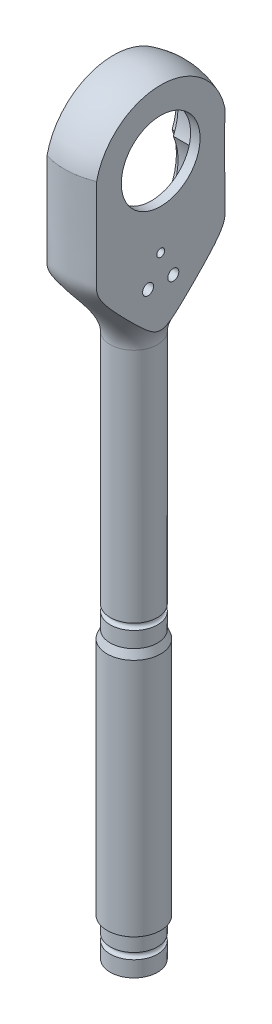
from build123d import *

# Parameters (mm, degrees)
WYTNIJ_WYCI_GNI_CIE1_DEPTH      = 248.984446753
WYTNIJ_WYCI_GNI_CIE1_DEPTH_BACK = 248.984446753
SZKIC2_W                        = 31.290574964
SZKIC2_H                        = 87.321210772
WYTNIJ_WYCI_GNI_CIE2_DEPTH      = 2
WYTNIJ_WYCI_GNI_CIE3_DEPTH      = 12
WYTNIJ_WYCI_GNI_CIE4_DEPTH      = 248.390668611
WYTNIJ_WYCI_GNI_CIE4_DEPTH_BACK = 248.390668611
SZKIC5_R                        = 1.75
SZKIC5_R_2                      = 1.25
SZKIC5_R_3                      = 12.5


with BuildPart() as part:
    # Szkic1 → Obrót1 (revolve)
    with BuildSketch(Plane.XY, mode=Mode.PRIVATE) as obr_t1_sk:
        with BuildLine():
            Line((0, 0), (7.5, 0))
            Line((7.5, 0), (7.5, 5))
            ThreePointArc((7.5, 5), (6.5, 6), (7.5, 7))
            Line((7.5, 7), (7.5, 11.25))
            ThreePointArc((7.5, 11.25), (7.719669914, 11.780330086), (8.25, 12))
            Line((8.25, 12), (8.5, 12))
            Line((8.5, 12), (8.5, 88))
            Line((8.5, 88), (7.5, 90.5))
            Line((7.5, 90.5), (7.5, 95.5))
            ThreePointArc((7.5, 95.5), (6.5, 96.5), (7.5, 97.5))
            Line((7.5, 97.5), (7.5, 172.5))
            add(Edge.make_bspline(
                [(7.5, 172.5), (7.5, 180.6), (22.382394371, 192.832212865), (21.895583134, 206.484053927), (22.045407685, 220.5), (22.045407685, 228)],
                knots=[0, 0, 0, 0, 0.361711038, 0.461711038, 1, 1, 1, 1], degree=3))
            ThreePointArc((22.045407685, 228), (14.230249471, 240.928425058), (0, 246))
            Line((0, 246), (0, 0))
        make_face()
    revolve(obr_t1_sk.sketch.rotate(Axis((0, 0, 0), (0, 1, 0)), 90), axis=Axis((0, 0, 0), (0, 1, 0)))

    # Szkic2 → Wytnij-wyciągnięcie1 (cut, two sides: drawn at the far end of the back side and taken through both)
    with BuildSketch(Plane.XY.offset(-WYTNIJ_WYCI_GNI_CIE1_DEPTH_BACK)):
        Polygon((-7.5, 168), (-6.5, 173), (-6.5, 255.321210772), (-63.324406691, 255.321210772), (-63.324406691, 168), align=None)
        with Locations((24.145287482, 211.660605386)):
            Rectangle(SZKIC2_W, SZKIC2_H)
    extrude(amount=WYTNIJ_WYCI_GNI_CIE1_DEPTH + WYTNIJ_WYCI_GNI_CIE1_DEPTH_BACK, mode=Mode.SUBTRACT)

    # Szkic3 → Wytnij-wyciągnięcie2 (cut)
    with BuildSketch(Plane.ZY.offset(6.5)):
        with BuildLine():
            ThreePointArc((18.639675426, 215.25), (0, 242.5), (-18.639675426, 215.25))
            ThreePointArc((-18.639675426, 215.25), (0, 188), (18.639675426, 215.25))
        make_face()
    extrude(amount=-WYTNIJ_WYCI_GNI_CIE2_DEPTH, mode=Mode.SUBTRACT)

    # Szkic4 → Wytnij-wyciągnięcie3 (cut)
    with BuildSketch(Plane.ZY.offset(6.5)):
        with BuildLine():
            ThreePointArc((-17.020208577, 215.25), (0, 189.5), (17.020208577, 215.25))
            ThreePointArc((17.020208577, 215.25), (0, 241), (-17.020208577, 215.25))
        make_face()
    extrude(amount=-WYTNIJ_WYCI_GNI_CIE3_DEPTH, mode=Mode.SUBTRACT)

    # Szkic5 → Wytnij-wyciągnięcie4 (cut, two sides: drawn at the far end of the back side and taken through both)
    with BuildSketch(Plane.ZY.offset(-5.5).offset(-WYTNIJ_WYCI_GNI_CIE4_DEPTH_BACK)):
        with Locations((4, 190.193751097)):
            Circle(SZKIC5_R)
        with Locations((-4, 190.193751097)):
            Circle(SZKIC5_R)
        with Locations((0, 198.256008845)):
            Circle(SZKIC5_R_2)
        with Locations((0, 223.5)):
            Circle(SZKIC5_R_3)
    extrude(amount=WYTNIJ_WYCI_GNI_CIE4_DEPTH + WYTNIJ_WYCI_GNI_CIE4_DEPTH_BACK, mode=Mode.SUBTRACT)


solid = part.part
